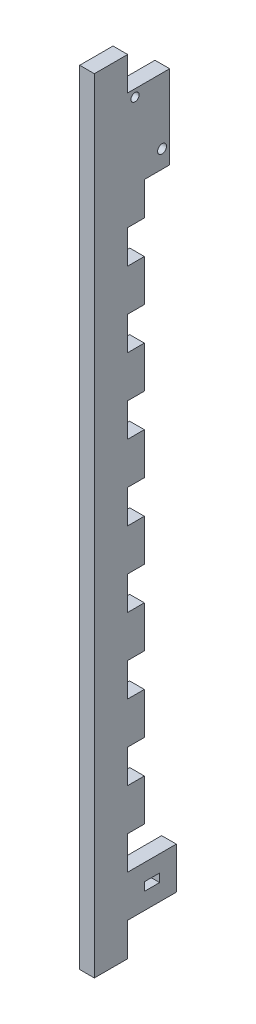
from build123d import *

# Parameters (mm, degrees)
BOSS_EXTRUDE1_DEPTH = 5.588
SKETCH2_W           = 15.9999934
SKETCH2_H           = 31.75
SKETCH2_R           = 1.55
SKETCH2_R_2         = 1.7
BOSS_EXTRUDE2_DEPTH = 5.588
SKETCH2_4_R         = 1.55
CUT_EXTRUDE1_DEPTH  = 6.588


with BuildPart() as part:
    # Sketch1 → Boss-Extrude1 (new body)
    with BuildSketch(Plane(origin=(0, 0, 0), x_dir=(0, 0, -1), z_dir=(1, 0, 0))):
        Polygon((3.175, 120.65), (9.525, 120.65), (9.525, 136.525), (3.175, 136.525), (3.175, 149.225), (-9.525, 149.225), (-9.525, -149.225), (3.175, -149.225), (3.175, -136.525), (9.525, -136.525), (9.525, -120.65), (3.175, -120.65), (3.175, -107.95), (9.525, -107.95), (9.525, -92.075), (3.175, -92.075), (3.175, -79.375), (9.525, -79.375), (9.525, -63.5), (3.175, -63.5), (3.175, -50.8), (9.525, -50.8), (9.525, -34.925), (3.175, -34.925), (3.175, -22.225), (9.525, -22.225), (9.525, -6.35), (3.175, -6.35), (3.175, 6.35), (9.525, 6.35), (9.525, 22.225), (3.175, 22.225), (3.175, 34.925), (9.525, 34.925), (9.525, 50.8), (3.175, 50.8), (3.175, 63.5), (9.525, 63.5), (9.525, 79.375), (3.175, 79.375), (3.175, 92.075), (9.525, 92.075), (9.525, 107.95), (3.175, 107.95), align=None)
    extrude(amount=BOSS_EXTRUDE1_DEPTH)

    # Sketch2 → Boss-Extrude2 (add)
    with BuildSketch(Plane(origin=(5.588, 0, 0), x_dir=(0, 0, -1), z_dir=(1, 0, 0))):
        Polygon((21.717, -120.65), (9.525, -120.65), (9.525, -127), (15.367, -127), (15.367, -130.175), (9.525, -130.175), (9.525, -136.525), (21.717, -136.525), align=None)
        with Locations((11.1749967, 120.65)):
            Rectangle(SKETCH2_W, SKETCH2_H)
        with Locations((5.9749992, 133.7250056)):
            Circle(SKETCH2_R, mode=Mode.SUBTRACT)
        with Locations((16.2749992, 111.5250056)):
            Circle(SKETCH2_R_2, mode=Mode.SUBTRACT)
    extrude(amount=-BOSS_EXTRUDE2_DEPTH)

    # Sketch2_4 → Cut-Extrude1 (cut, through all)
    with BuildSketch(Plane(origin=(5.588, 0, 0), x_dir=(0, 0, -1), z_dir=(1, 0, 0))):
        with Locations((5.9749992, 133.7250056)):
            Circle(SKETCH2_4_R)
    extrude(amount=-CUT_EXTRUDE1_DEPTH, mode=Mode.SUBTRACT)


solid = part.part
